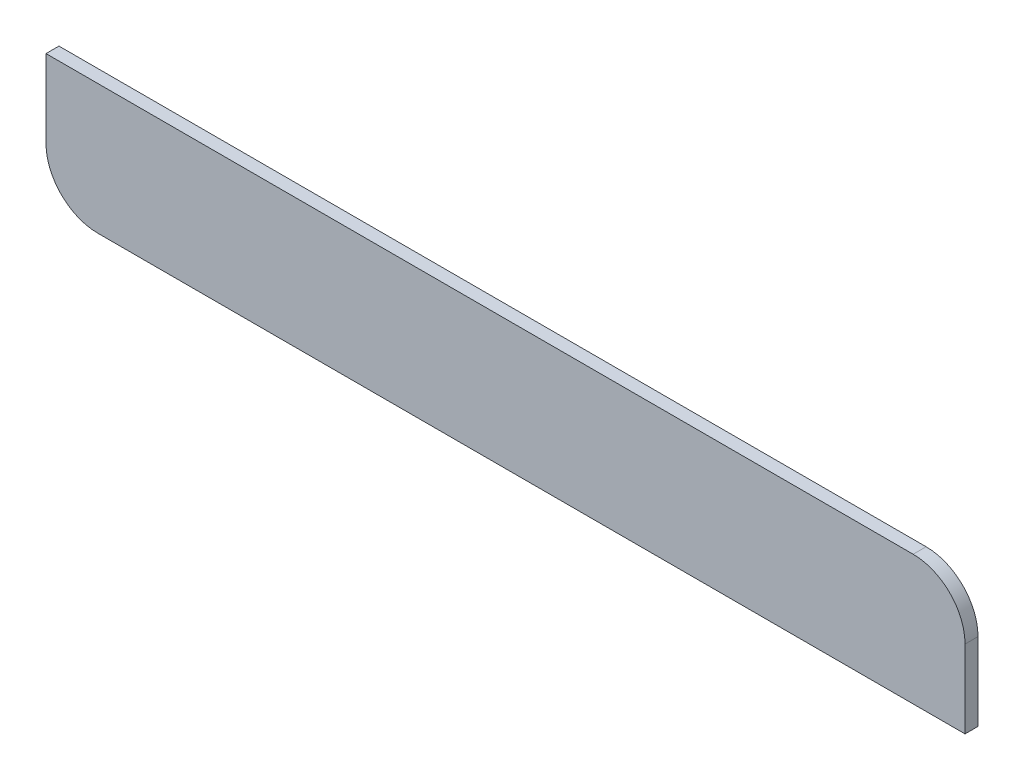
from build123d import *

# Parameters (mm, degrees)
BOSS_EXTRUDE1_DEPTH = 6.35


with BuildPart() as part:
    # Sketch1 → Boss-Extrude1 (new body)
    with BuildSketch(Plane.XY):
        with BuildLine():
            Line((-60.682247835, -10.121504584), (363.917752165, -10.121504584))
            ThreePointArc((363.917752165, -10.121504584), (381.878264407, -17.560992342), (389.317752165, -35.521504584))
            Line((389.317752165, -35.521504584), (389.317752165, -73.621504584))
            Line((389.317752165, -73.621504584), (-35.282247835, -73.621504584))
            ThreePointArc((-35.282247835, -73.621504584), (-53.242760077, -66.182016826), (-60.682247835, -48.221504584))
            Line((-60.682247835, -48.221504584), (-60.682247835, -10.121504584))
        make_face()
    extrude(amount=BOSS_EXTRUDE1_DEPTH)


solid = part.part
